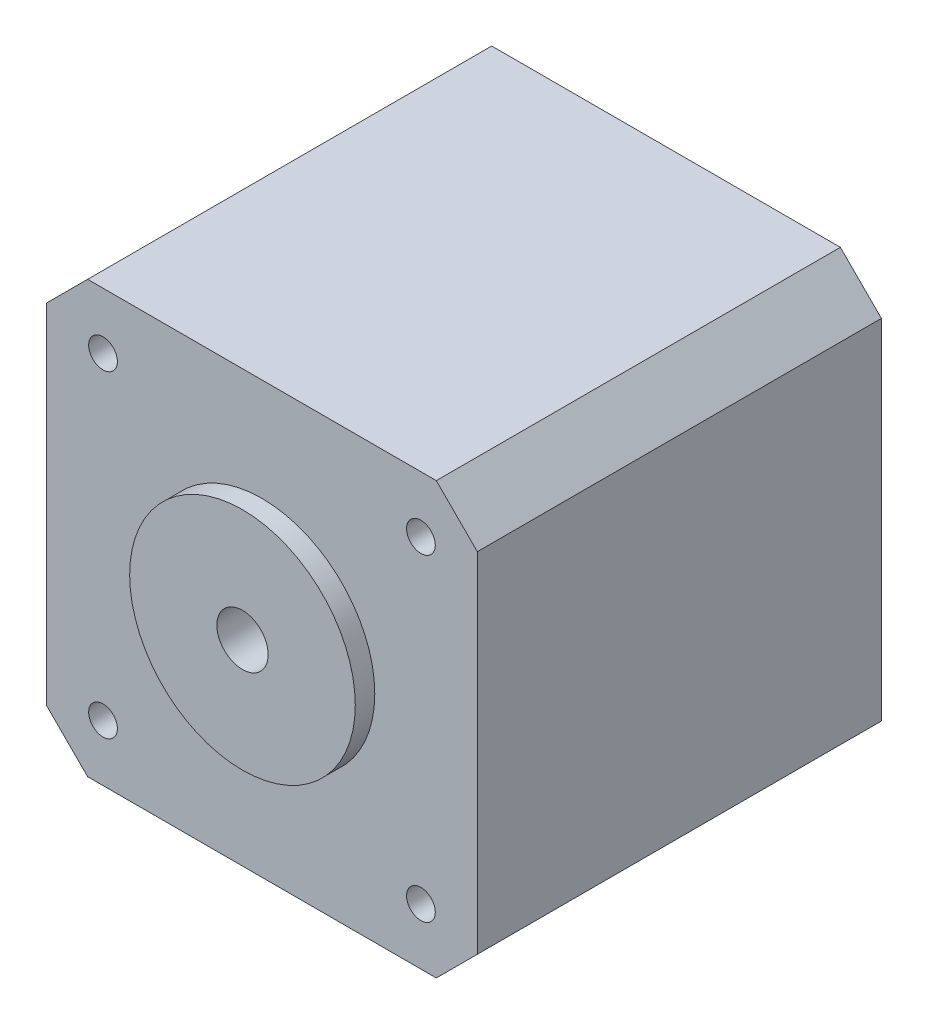
from build123d import *

# Parameters (mm, degrees)
CROQUIS1_W                          = 42
CROQUIS1_H                          = 42
SALIENTE_EXTRUIR1_DEPTH             = 39.4
CROQUIS2_W                          = 10.5
CROQUIS2_H                          = 16
SALIENTE_EXTRUIR2_DEPTH             = 6.5
CROQUIS3_R                          = 11
SALIENTE_EXTRUIR3_DEPTH             = 1.9
CROQUIS4_R                          = 2.45
SALIENTE_EXTRUIR4_DEPTH             = 20.4
CORTAR_EXTRUIR1_DEPTH               = 15
DI_METRO_DE_TALADRO_2_8_2_8_1_D     = 2.8
DI_METRO_DE_TALADRO_2_8_2_8_1_DEPTH = 3
CHAFL_N1_SIZE                       = 4
CROQUIS8_R                          = 2.5
CORTAR_EXTRUIR2_DEPTH               = 62.7


with BuildPart() as part:
    # Croquis1 → Saliente-Extruir1 (new body)
    with BuildSketch(Plane(origin=(0, 0, 0), x_dir=(-1, 0, 0), z_dir=(0, 0, -1))):
        with Locations((-21, 21)):
            Rectangle(CROQUIS1_W, CROQUIS1_H)
    extrude(amount=-SALIENTE_EXTRUIR1_DEPTH)

    # Croquis2 → Saliente-Extruir2 (add)
    with BuildSketch(Plane.ZY):
        with Locations((5.25, 21)):
            Rectangle(CROQUIS2_W, CROQUIS2_H)
    extrude(amount=SALIENTE_EXTRUIR2_DEPTH)

    # Croquis3 → Saliente-Extruir3 (add)
    with BuildSketch(Plane.XY.offset(39.4)):
        with Locations((21, 21)):
            Circle(CROQUIS3_R)
    extrude(amount=SALIENTE_EXTRUIR3_DEPTH)

    # Croquis4 → Saliente-Extruir4 (add)
    with BuildSketch(Plane.XY.offset(41.3)):
        with Locations((21, 21)):
            Circle(CROQUIS4_R)
    extrude(amount=SALIENTE_EXTRUIR4_DEPTH)

    # Croquis5 → Cortar-Extruir1 (cut)
    with BuildSketch(Plane.XY.offset(61.7)):
        with BuildLine():
            Line((22.99, 22.429125607), (22.99, 19.570874393))
            ThreePointArc((22.99, 19.570874393), (23.45, 21), (22.99, 22.429125607))
        make_face()
    extrude(amount=-CORTAR_EXTRUIR1_DEPTH, mode=Mode.SUBTRACT)

    # Diámetro de taladro Ø2.8 (2.8)1
    with Locations(Plane.XY.offset(39.4)):
        with Locations((36.5, 5.5), (5.5, 5.5), (36.5, 36.5), (5.5, 36.5)):
            Hole(DI_METRO_DE_TALADRO_2_8_2_8_1_D / 2, depth=DI_METRO_DE_TALADRO_2_8_2_8_1_DEPTH)

    # Chaflán1
    chafl_n1_edges = [part.edges().sort_by_distance(p)[0] for p in [
        (42, 0, 19.7),
        (42, 42, 19.7),
        (0, 42, 19.7),
        (0, 0, 19.7),
    ]]
    chamfer(chafl_n1_edges, length=CHAFL_N1_SIZE)

    # Croquis8 → Cortar-Extruir2 (cut, through all)
    with BuildSketch(Plane.XY.offset(61.7)):
        with Locations((21, 21)):
            Circle(CROQUIS8_R)
    extrude(amount=-CORTAR_EXTRUIR2_DEPTH, mode=Mode.SUBTRACT)


solid = part.part
